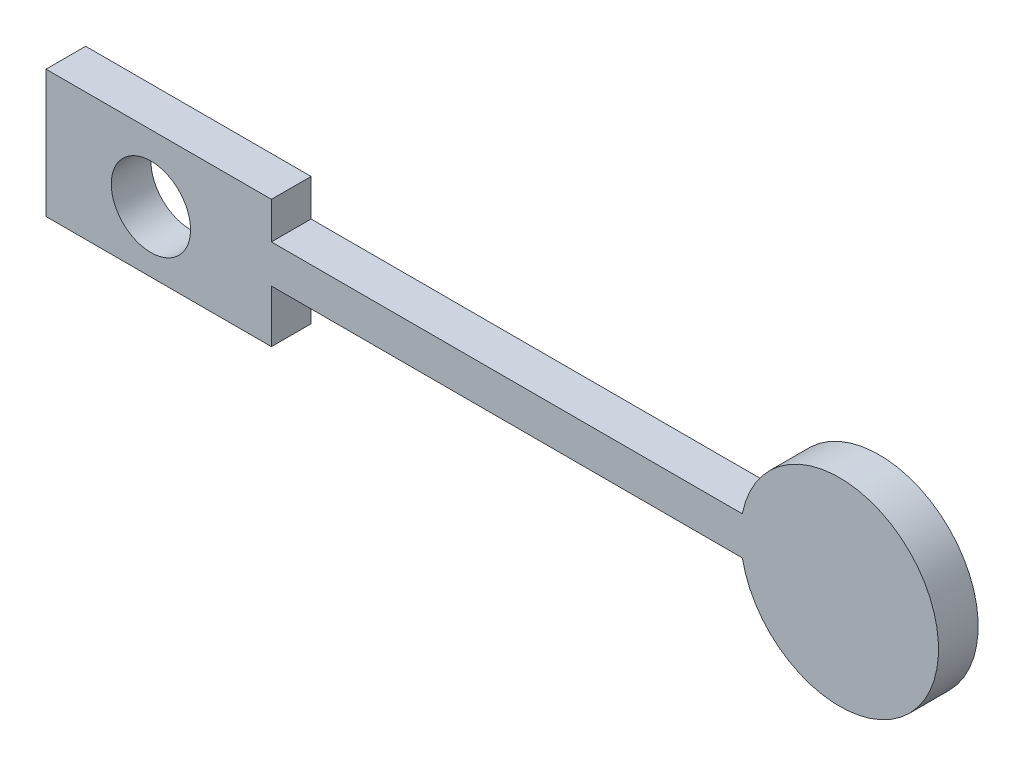
from build123d import *

# Parameters (mm, degrees)
SKETCH1_R           = 10
BOSS_EXTRUDE1_DEPTH = 10


with BuildPart() as part:
    # Sketch1 → Boss-Extrude1 (new body)
    with BuildSketch(Plane.XY):
        with BuildLine():
            Line((30.40998342, 7.530623632), (30.40998342, 16.840305532))
            Line((30.40998342, 16.840305532), (-26.463337265, 16.840305532))
            Line((-26.463337265, 16.840305532), (-26.463337265, -15.359839112))
            Line((-26.463337265, -15.359839112), (30.40998342, -15.359839112))
            Line((30.40998342, -15.359839112), (30.40998342, -2.10831855))
            Line((30.40998342, -2.10831855), (149.211555262, -2.10831855))
            ThreePointArc((149.211555262, -2.10831855), (198.71742784, 2.711152541), (149.211555262, 7.530623632))
            Line((149.211555262, 7.530623632), (30.40998342, 7.530623632))
        make_face()
        Circle(SKETCH1_R, mode=Mode.SUBTRACT)
    extrude(amount=BOSS_EXTRUDE1_DEPTH)


solid = part.part
